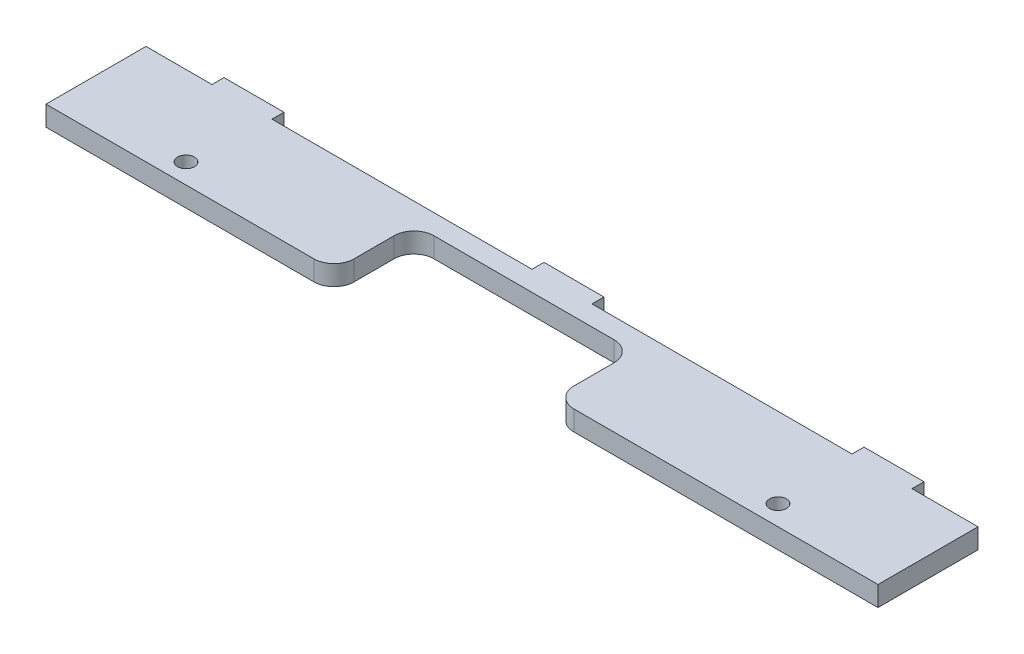
from build123d import *

# Parameters (mm, degrees)
SKETCH1_W            = 208
SKETCH1_H            = 25
BOSS_EXTRUDE1_DEPTH  = 5
SURUCU_BOSLUGU_DEPTH = 6
SKETCH7_R            = 2.1
KASA_BAGLANTI_DEPTH  = 6
SKETCH8_W            = 15
SKETCH8_H            = 3
YAN_BAGLANTI_DEPTH   = 5


with BuildPart() as part:
    # Sketch1 → Boss-Extrude1 (new body)
    with BuildSketch(Plane(origin=(0, 0, 0), x_dir=(1, 0, 0), z_dir=(0, 1, 0))):
        with Locations((44.254700849, 4.167980547)):
            Rectangle(SKETCH1_W, SKETCH1_H)
    extrude(amount=BOSS_EXTRUDE1_DEPTH)

    # Sketch6 → Surucu Boslugu (cut, through all)
    with BuildSketch(Plane(origin=(0, 0, 0), x_dir=(-1, 0, 0), z_dir=(0, -1, 0))):
        with BuildLine():
            Line((-72.254700849, -8.332019453), (-7.254700849, -8.332019453))
            ThreePointArc((-7.254700849, -8.332019453), (-10.790234755, -6.867553359), (-12.254700849, -3.332019453))
            Line((-12.254700849, -3.332019453), (-12.254700849, 6.667980547))
            ThreePointArc((-12.254700849, 6.667980547), (-13.719166943, 10.203514453), (-17.254700849, 11.667980547))
            Line((-17.254700849, 11.667980547), (-62.254700849, 11.667980547))
            ThreePointArc((-62.254700849, 11.667980547), (-65.790234755, 10.203514453), (-67.254700849, 6.667980547))
            Line((-67.254700849, 6.667980547), (-67.254700849, -3.332019453))
            ThreePointArc((-67.254700849, -3.332019453), (-68.719166943, -6.867553359), (-72.254700849, -8.332019453))
        make_face()
    extrude(amount=-SURUCU_BOSLUGU_DEPTH, mode=Mode.SUBTRACT)

    # Sketch7 → Kasa Baglanti (cut, through all)
    with BuildSketch(Plane.XZ):
        with Locations((-29.745299151, 3.332019453)):
            Circle(SKETCH7_R)
        with Locations((118.254700849, 3.332019453)):
            Circle(SKETCH7_R)
    extrude(amount=-KASA_BAGLANTI_DEPTH, mode=Mode.SUBTRACT)

    # Sketch8 → Yan Baglanti (add, through all)
    with BuildSketch(Plane.XZ):
        with Locations((124.254700849, -18.167980547)):
            Rectangle(SKETCH8_W, SKETCH8_H)
        with Locations((44.254700849, -18.167980547)):
            Rectangle(SKETCH8_W, SKETCH8_H)
        with Locations((-35.745299151, -18.167980547)):
            Rectangle(SKETCH8_W, SKETCH8_H)
    extrude(amount=-YAN_BAGLANTI_DEPTH)


solid = part.part
